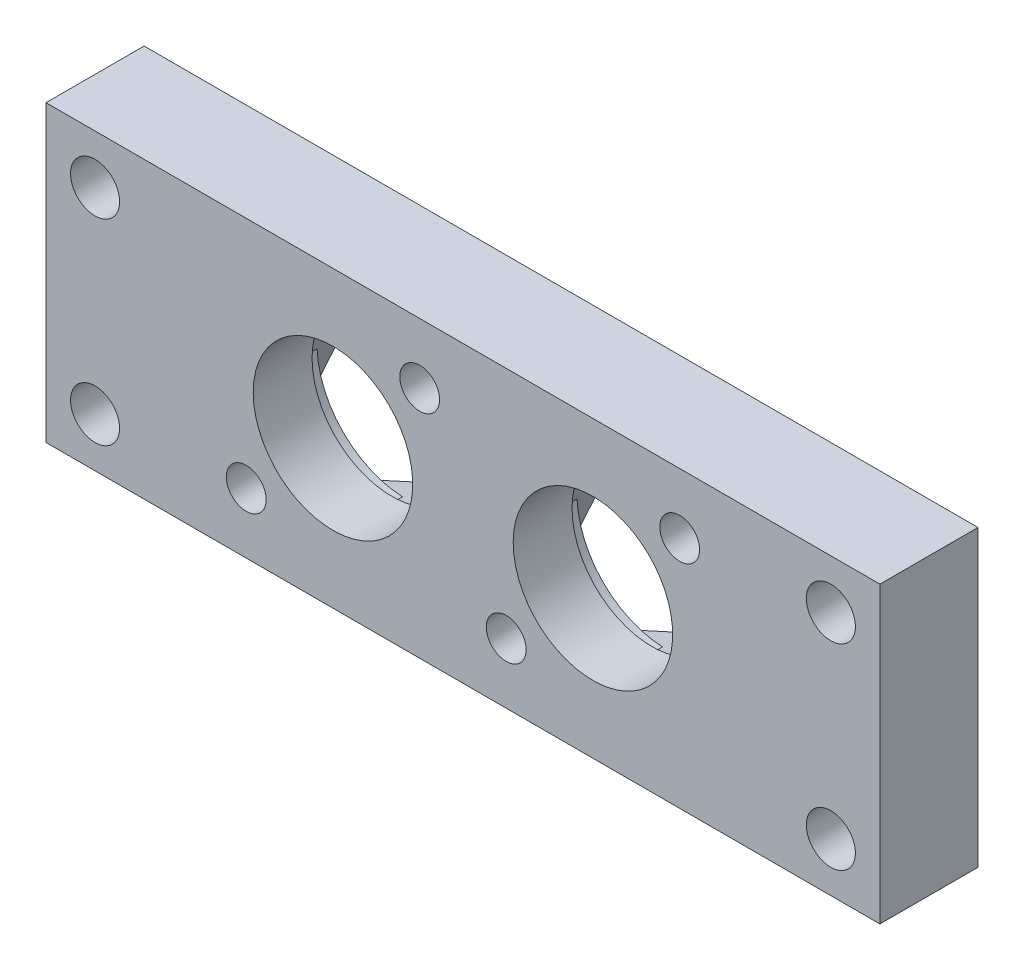
from build123d import *

# Parameters (mm, degrees)
SKETCH1_W           = 215.9
SKETCH1_H           = 76.2
BOSS_EXTRUDE1_DEPTH = 12.7
SKETCH2_R           = 5.159375
SKETCH2_R_2         = 6.985
BOSS_EXTRUDE2_DEPTH = 9.525
SKETCH3_R           = 5.159375
BOSS_EXTRUDE3_DEPTH = 9.525
CUT_EXTRUDE1_DEPTH  = 3.81
LPATTERN1_COUNT     = 2
LPATTERN1_PITCH     = 67.31
SKETCH5_R           = 13.335
CUT_EXTRUDE2_DEPTH  = 2.54
SKETCH6_R           = 6.35
CUT_EXTRUDE3_DEPTH  = 118.260276735
SKETCH7_R           = 20.6502
CUT_EXTRUDE4_DEPTH  = 116.571744492


with BuildPart() as part:
    # Sketch1 → Boss-Extrude1 (new, symmetric)
    with BuildSketch(Plane.XY):
        Rectangle(SKETCH1_W, SKETCH1_H)
        with BuildLine():
            ThreePointArc((-52.148499203, -31.128702045), (-62.84981265, -29.19481265), (-64.783702045, -18.493499203))
            Line((-64.783702045, -18.493499203), (-52.443985877, 8.56765836))
            ThreePointArc((-52.443985877, 8.56765836), (-48.256896453, 14.601896453), (-42.22265836, 18.788985877))
            Line((-42.22265836, 18.788985877), (-15.161500797, 31.128702045))
            ThreePointArc((-15.161500797, 31.128702045), (-6.045595474, 30.472789203), (-1.666659697, 22.450640303))
            ThreePointArc((-1.666659697, 22.450640303), (-1.884046645, 20.42592158), (-2.526297955, 18.493499203))
            Line((-2.526297955, 18.493499203), (-14.866014123, -8.56765836))
            ThreePointArc((-14.866014123, -8.56765836), (-19.053103547, -14.601896453), (-25.08734164, -18.788985877))
            Line((-25.08734164, -18.788985877), (-52.148499203, -31.128702045))
        make_face(mode=Mode.SUBTRACT)
        with BuildLine():
            Line((64.783702045, 18.493499203), (52.443985877, -8.56765836))
            ThreePointArc((52.443985877, -8.56765836), (48.256896453, -14.601896453), (42.22265836, -18.788985877))
            Line((42.22265836, -18.788985877), (15.161500797, -31.128702045))
            ThreePointArc((15.161500797, -31.128702045), (4.46018735, -29.19481265), (2.526297955, -18.493499203))
            Line((2.526297955, -18.493499203), (14.866014123, 8.56765836))
            ThreePointArc((14.866014123, 8.56765836), (19.053103547, 14.601896453), (25.08734164, 18.788985877))
            Line((25.08734164, 18.788985877), (52.148499203, 31.128702045))
            ThreePointArc((52.148499203, 31.128702045), (61.264404526, 30.472789203), (65.643340303, 22.450640303))
            ThreePointArc((65.643340303, 22.450640303), (65.425953355, 20.42592158), (64.783702045, 18.493499203))
        make_face(mode=Mode.SUBTRACT)
    extrude(amount=BOSS_EXTRUDE1_DEPTH, both=True)

    # Sketch2 → Boss-Extrude2 (add)
    with BuildSketch(Plane.XY.offset(12.7)):
        with BuildLine():
            Line((-64.783702045, -18.493499203), (-52.443985877, 8.56765836))
            ThreePointArc((-52.443985877, 8.56765836), (-48.256896453, 14.601896453), (-42.22265836, 18.788985877))
            Line((-42.22265836, 18.788985877), (-15.161500797, 31.128702045))
            ThreePointArc((-15.161500797, 31.128702045), (-4.46018735, 29.19481265), (-2.526297955, 18.493499203))
            Line((-2.526297955, 18.493499203), (-14.866014123, -8.56765836))
            ThreePointArc((-14.866014123, -8.56765836), (-19.053103547, -14.601896453), (-25.08734164, -18.788985877))
            Line((-25.08734164, -18.788985877), (-52.148499203, -31.128702045))
            ThreePointArc((-52.148499203, -31.128702045), (-62.84981265, -29.19481265), (-64.783702045, -18.493499203))
        make_face()
        with Locations((-11.204359697, 22.450640303)):
            Circle(SKETCH2_R, mode=Mode.SUBTRACT)
        with Locations((-56.105640303, -22.450640303)):
            Circle(SKETCH2_R, mode=Mode.SUBTRACT)
        with Locations((-33.655, 0)):
            Circle(SKETCH2_R_2, mode=Mode.SUBTRACT)
    boss_extrude2 = extrude(amount=-BOSS_EXTRUDE2_DEPTH)

    # Sketch3 → Boss-Extrude3 (add)
    with BuildSketch(Plane(origin=(0, 0, 3.175), x_dir=(-1, 0, 0), z_dir=(0, 0, -1))):
        with BuildLine():
            ThreePointArc((14.866014123, -8.56765836), (19.053103547, 14.601896453), (42.22265836, 18.788985877))
            Line((42.22265836, 18.788985877), (15.161500797, 31.128702045))
            ThreePointArc((15.161500797, 31.128702045), (4.46018735, 29.19481265), (2.526297955, 18.493499203))
            Line((2.526297955, 18.493499203), (14.866014123, -8.56765836))
        make_face()
        with Locations(Location((11.204359697, 22.450640303, 0), (0, 0, 180))):
            Circle(SKETCH3_R, mode=Mode.SUBTRACT)
        with BuildLine():
            Line((64.783702045, -18.493499203), (52.443985877, 8.56765836))
            ThreePointArc((52.443985877, 8.56765836), (53.834532653, 4.383745196), (54.3052, 0))
            ThreePointArc((54.3052, 0), (44.824308425, -17.368860335), (25.08734164, -18.788985877))
            Line((25.08734164, -18.788985877), (52.148499203, -31.128702045))
            ThreePointArc((52.148499203, -31.128702045), (62.84981265, -29.19481265), (64.783702045, -18.493499203))
        make_face()
        with Locations(Location((56.105640303, -22.450640303, 0), (0, 0, 180))):
            Circle(SKETCH3_R, mode=Mode.SUBTRACT)
    boss_extrude3 = extrude(amount=BOSS_EXTRUDE3_DEPTH)

    # Sketch4 → Cut-Extrude1 (cut)
    with BuildSketch(Plane(origin=(0, 0, -6.35), x_dir=(-1, 0, 0), z_dir=(0, 0, -1))):
        with BuildLine():
            ThreePointArc((32.621288713, 23.167149523), (17.257052323, 16.397947677), (10.487850477, 1.033711287))
            Line((10.487850477, 1.033711287), (14.866014123, -8.56765836))
            ThreePointArc((14.866014123, -8.56765836), (19.053103547, 14.601896453), (42.22265836, 18.788985877))
            Line((42.22265836, 18.788985877), (32.621288713, 23.167149523))
        make_face()
        with BuildLine():
            Line((25.08734164, -18.788985877), (34.688711287, -23.167149523))
            ThreePointArc((34.688711287, -23.167149523), (50.052947677, -16.397947677), (56.822149523, -1.033711287))
            Line((56.822149523, -1.033711287), (52.443985877, 8.56765836))
            ThreePointArc((52.443985877, 8.56765836), (53.834532653, 4.383745196), (54.3052, 0))
            ThreePointArc((54.3052, 0), (44.824308425, -17.368860335), (25.08734164, -18.788985877))
        make_face()
    cut_extrude1 = extrude(amount=-CUT_EXTRUDE1_DEPTH, mode=Mode.SUBTRACT)

    # LPattern1: Boss-Extrude2, Boss-Extrude3, Cut-Extrude1 ×2
    with Locations(*[(i * LPATTERN1_PITCH, 0, 0) for i in range(1, LPATTERN1_COUNT)]):
        add(boss_extrude2)
        add(boss_extrude3)
        add(cut_extrude1, mode=Mode.SUBTRACT)

    # Sketch5 → Cut-Extrude2 (cut)
    with BuildSketch(Plane(origin=(0, 0, 3.175), x_dir=(-1, 0, 0), z_dir=(0, 0, -1))):
        with Locations((33.655, 0)):
            Circle(SKETCH5_R)
        with Locations((-33.655, 0)):
            Circle(SKETCH5_R)
    extrude(amount=-CUT_EXTRUDE2_DEPTH, mode=Mode.SUBTRACT)

    # Sketch6 → Cut-Extrude3 (cut, through all)
    with BuildSketch(Plane(origin=(0, 0, -12.7), x_dir=(-1, 0, 0), z_dir=(0, 0, -1))):
        with Locations((-95.25, 25.4)):
            Circle(SKETCH6_R)
        with Locations((-95.25, -25.4)):
            Circle(SKETCH6_R)
        with Locations(Location((95.25, -25.4, 0), (0, 0, 180))):
            Circle(SKETCH6_R)
        with Locations(Location((95.25, 25.4, 0), (0, 0, 180))):
            Circle(SKETCH6_R)
    extrude(amount=-CUT_EXTRUDE3_DEPTH, mode=Mode.SUBTRACT)

    # Sketch7 → Cut-Extrude4 (cut, through all)
    with BuildSketch(Plane(origin=(0, 0, 3.175), x_dir=(-1, 0, 0), z_dir=(0, 0, -1))):
        with Locations((-33.655, 0)):
            Circle(SKETCH7_R)
        with Locations((33.655, 0)):
            Circle(SKETCH7_R)
    extrude(amount=-CUT_EXTRUDE4_DEPTH, mode=Mode.SUBTRACT)


solid = part.part
